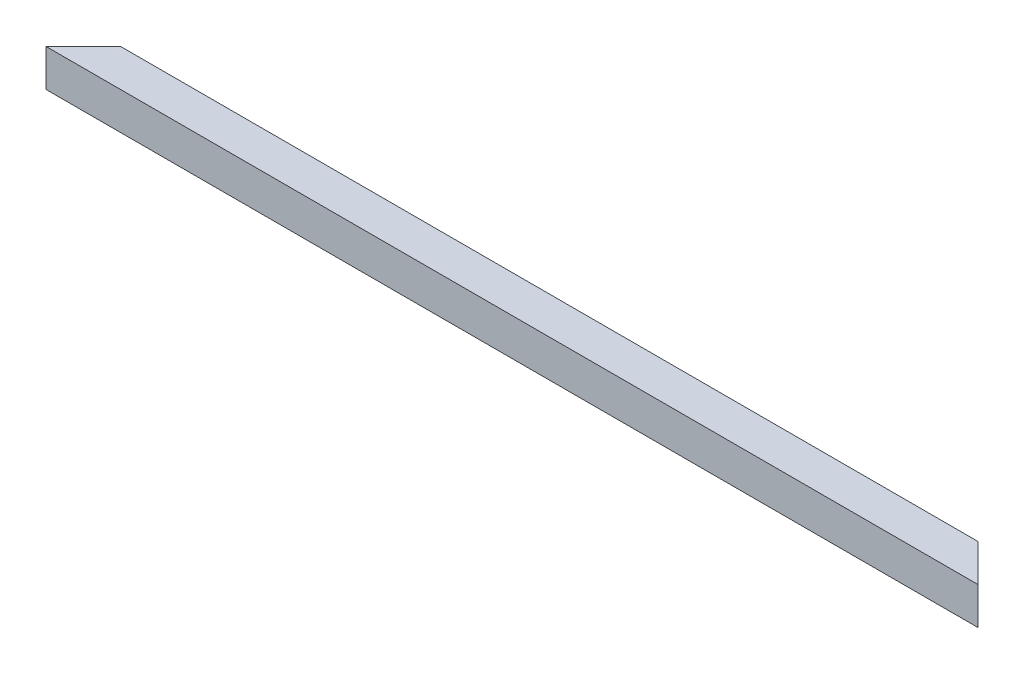
from build123d import *

# Parameters (mm, degrees)
CROQUIS1_W              = 40
CROQUIS1_H              = 40
CROQUIS1_W_2            = 36
CROQUIS1_H_2            = 36
SALIENTE_EXTRUIR1_DEPTH = 1000
CORTAR_EXTRUIR1_DEPTH   = 41


with BuildPart() as part:
    # Croquis1 → Saliente-Extruir1 (new body)
    with BuildSketch(Plane(origin=(0, 0, 0), x_dir=(0, 0, -1), z_dir=(1, 0, 0))):
        Rectangle(CROQUIS1_W, CROQUIS1_H)
        Rectangle(CROQUIS1_W_2, CROQUIS1_H_2, mode=Mode.SUBTRACT)
    extrude(amount=SALIENTE_EXTRUIR1_DEPTH)

    # Croquis2 → Cortar-Extruir1 (cut, through all)
    with BuildSketch(Plane(origin=(0, 20, 0), x_dir=(1, 0, 0), z_dir=(0, 1, 0))):
        Polygon((0, -20), (40, 20), (0, 20), align=None)
        Polygon((1000, 20), (1000, -20), (960, 20), align=None)
    extrude(amount=-CORTAR_EXTRUIR1_DEPTH, mode=Mode.SUBTRACT)


solid = part.part
